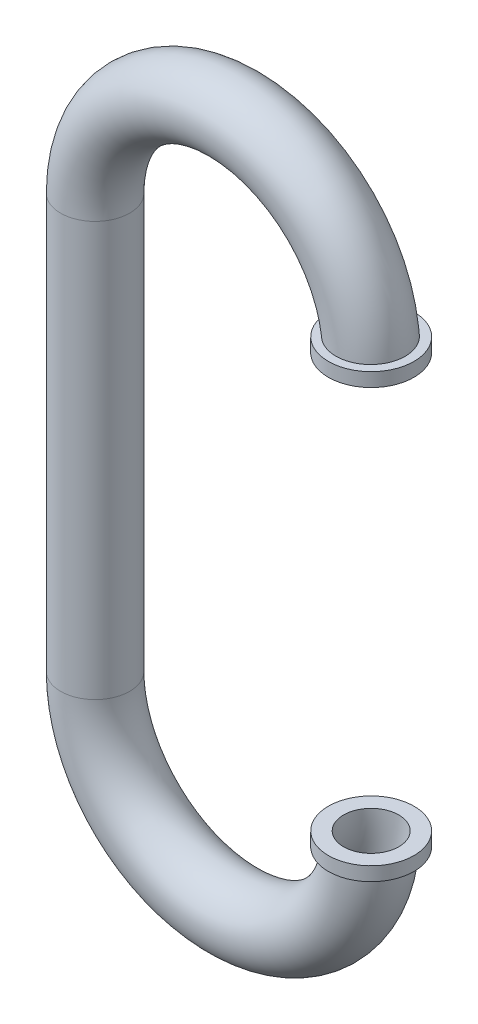
from build123d import *

# Parameters (mm, degrees)
IZIM4_R   = 0.25
IZIM4_R_2 = 0.2
IZIM5_R   = 0.31
IZIM5_R_2 = 0.21
IZIM6_R   = 0.31
IZIM6_R_2 = 0.21


with BuildPart() as part:
    # Süpür-İnce1: sweep along a path in Çizim1
    with BuildLine(Plane.XY) as s_p_r_nce1_path:
        ThreePointArc((0, 0), (-0.292893219, 0.707106781), (-1, 1))
        ThreePointArc((-1, 1), (-1.707106781, 0.707106781), (-2, 0))
        Line((-2, 0), (-2, -3))
        ThreePointArc((-2, -3), (-1.707106781, -3.707106781), (-1, -4))
        ThreePointArc((-1, -4), (-0.292893219, -3.707106781), (0, -3))
    # Çizim4 → Süpür-İnce1 (sweep)
    with BuildSketch(Plane(origin=(0, 0, 0), x_dir=(1, 0, 0), z_dir=(0, 1, 0))):
        Circle(IZIM4_R)
        Circle(IZIM4_R_2, mode=Mode.SUBTRACT)
    sweep(path=s_p_r_nce1_path.line)

    # Süpür-İnce2: sweep along a path in Çizim2
    with BuildLine(Plane.XY) as s_p_r_nce2_path:
        Line((0, 0), (0, 0.1))
    # Çizim5 → Süpür-İnce2 (sweep)
    with BuildSketch(Plane(origin=(0, 0, 0), x_dir=(1, 0, 0), z_dir=(0, 1, 0))):
        Circle(IZIM5_R)
        Circle(IZIM5_R_2, mode=Mode.SUBTRACT)
    sweep(path=s_p_r_nce2_path.line)

    # Süpür-İnce3: sweep along a path in Çizim3
    with BuildLine(Plane.XY) as s_p_r_nce3_path:
        Line((0, -3), (0, -3.1))
    # Çizim6 → Süpür-İnce3 (sweep)
    with BuildSketch(Plane(origin=(0, -3, 0), x_dir=(1, 0, 0), z_dir=(0, 1, 0))):
        Circle(IZIM6_R)
        Circle(IZIM6_R_2, mode=Mode.SUBTRACT)
    sweep(path=s_p_r_nce3_path.line)


solid = part.part
